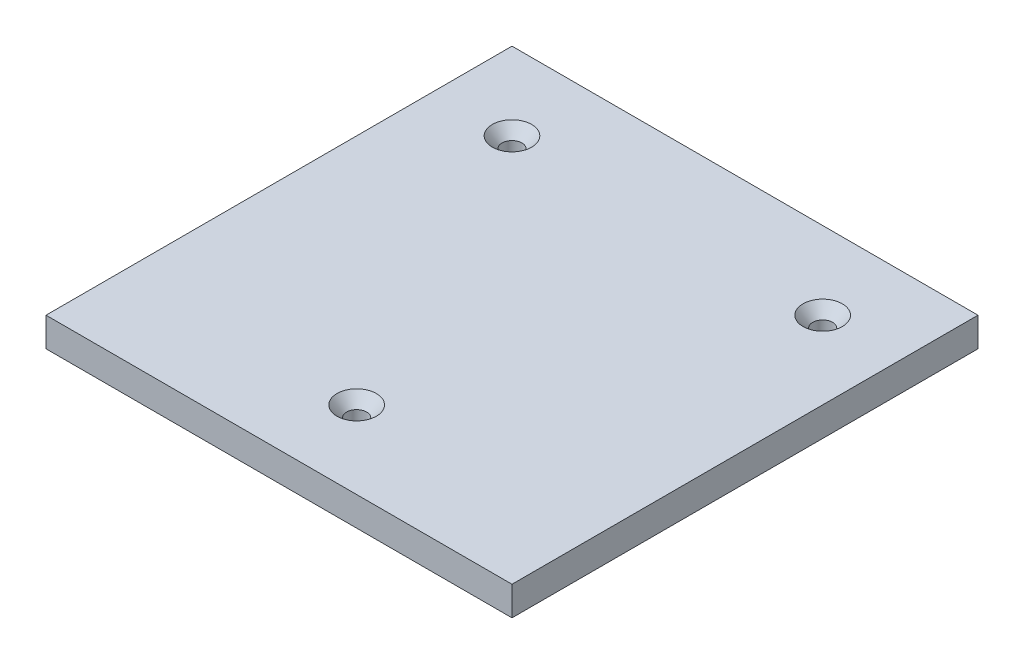
from build123d import *

# Parameters (mm, degrees)
SKETCH1_W                                        = 152.4
SKETCH1_H                                        = 152.4
EXTRUDE1_DEPTH                                   = 9.525
SKETCH16_W                                       = 1.527820346
SKETCH16_H                                       = 0.474151141
CUT_EXTRUDE3_DEPTH                               = 0.127
CSK_FOR_1_4_FLAT_HEAD_MACHINE_SCREW1_D           = 6.5278
CSK_FOR_1_4_FLAT_HEAD_MACHINE_SCREW1_CSINK_D     = 12.8778
CSK_FOR_1_4_FLAT_HEAD_MACHINE_SCREW1_CSINK_ANGLE = 82
LPATTERN2_COUNT                                  = 3
LPATTERN2_PITCH                                  = 50.8
LPATTERN2_COUNT_DIR2                             = 3
LPATTERN2_PITCH_DIR2                             = 50.8


with BuildPart() as part:
    # Sketch1 → Extrude1 (new body)
    with BuildSketch(Plane(origin=(0, 0, 0), x_dir=(1, 0, 0), z_dir=(0, 1, 0))):
        Rectangle(SKETCH1_W, SKETCH1_H)
    extrude(amount=EXTRUDE1_DEPTH)

    # Sketch16 → Cut-Extrude3 (cut)
    with BuildSketch(Plane(origin=(0, 0, -76.2), x_dir=(-1, 0, 0), z_dir=(0, 0, -1))):
        with BuildLine():
            Line((-21.995344635, 2.54), (-21.995344635, 6.649309896))
            Line((-21.995344635, 6.649309896), (-20.456822961, 6.649309896))
            add(Edge.make_bspline(
                [(-20.456822961, 6.649309896), (-20.418670168, 6.649163533), (-20.344223223, 6.648877936), (-20.235515289, 6.641735465), (-20.132560757, 6.631966046), (-20.035137992, 6.619372964), (-19.943668539, 6.601100659), (-19.858237639, 6.578964983), (-19.778400711, 6.553432196), (-19.680812231, 6.514537491), (-19.568352208, 6.454670273), (-19.44789684, 6.365338936), (-19.343095989, 6.258084044), (-19.256860301, 6.135110237), (-19.185811395, 6.003751019), (-19.135438552, 5.866508908), (-19.103232465, 5.726371998), (-19.099578309, 5.63148124), (-19.097754324, 5.584116185)],
                knots=[0, 0, 0, 0, 0.939712594, 1.833646414, 2.682508961, 3.487467313, 4.25240329, 4.978730417, 5.660668875, 6.315918528, 7.564895217, 8.787077865, 9.996481721, 11.241996224, 12.475862915, 13.665015424, 14.834484263, 16, 16, 16, 16], degree=3))
            add(Edge.make_bspline(
                [(-19.097754324, 5.584116185), (-19.099671717, 5.540049426), (-19.103488018, 5.452340752), (-19.133861507, 5.323140541), (-19.181800165, 5.197687941), (-19.249586784, 5.077508077), (-19.33622658, 4.964799613), (-19.443635186, 4.863375963), (-19.57026915, 4.773019762), (-19.665307935, 4.724857251), (-19.714315444, 4.700021868)],
                knots=[0, 0, 0, 0, 0.926741525, 1.844548388, 2.778836836, 3.746021974, 4.738420572, 5.759761325, 6.844803049, 8, 8, 8, 8], degree=3))
            add(Edge.make_bspline(
                [(-19.714315444, 4.700021868), (-19.683999074, 4.690531545), (-19.624644781, 4.671951105), (-19.539316819, 4.637951508), (-19.459219921, 4.5992381), (-19.384179741, 4.555747265), (-19.314703314, 4.507076257), (-19.250986677, 4.453149199), (-19.192588046, 4.394800599), (-19.139611757, 4.33206595), (-19.093077645, 4.265348962), (-19.05134236, 4.196107806), (-19.016879177, 4.123508665), (-18.988630961, 4.047740025), (-18.966593153, 3.96927007), (-18.950767608, 3.887796991), (-18.941747451, 3.803510432), (-18.940392653, 3.746252855), (-18.939703943, 3.717146064)],
                knots=[0, 0, 0, 0, 1.127427615, 2.20731145, 3.257257018, 4.283066884, 5.282973838, 6.264540225, 7.242620376, 8.210460609, 9.17525685, 10.12748095, 11.077310519, 12.023587065, 12.994999128, 13.967387486, 14.966724908, 16, 16, 16, 16], degree=3))
            add(Edge.make_bspline(
                [(-18.939703943, 3.717146064), (-18.941123478, 3.670415518), (-18.943937171, 3.57778989), (-18.966534255, 3.441460543), (-19.00472213, 3.310323201), (-19.057284492, 3.186498196), (-19.119914662, 3.072003749), (-19.191096044, 2.969837698), (-19.269013367, 2.881051323), (-19.355860701, 2.806366113), (-19.451077844, 2.742980225), (-19.557354131, 2.689605162), (-19.673867854, 2.642533471), (-19.802987088, 2.604930867), (-19.944653059, 2.575059407), (-20.100788303, 2.555651871), (-20.2716327, 2.541758677), (-20.390662074, 2.540602609), (-20.452707066, 2.54)],
                knots=[0, 0, 0, 0, 1.028073207, 2.037766189, 3.031549473, 4.027532207, 4.992436545, 5.898794514, 6.762903869, 7.584966804, 8.412380356, 9.273953678, 10.198004568, 11.174406109, 12.229717296, 13.381036288, 14.634844708, 16, 16, 16, 16], degree=3))
            Line((-20.452707066, 2.54), (-21.995344635, 2.54))
        make_face()
        with BuildLine():
            Line((-21.415826573, 4.910755709), (-20.568775314, 4.910755709))
            add(Edge.make_bspline(
                [(-20.568775314, 4.910755709), (-20.541057688, 4.910865371), (-20.487805867, 4.911076055), (-20.410991384, 4.914013623), (-20.340095298, 4.916519789), (-20.275391845, 4.922810073), (-20.216560478, 4.928971126), (-20.163836634, 4.937264865), (-20.116962068, 4.946610026), (-20.088260764, 4.955278367), (-20.074867875, 4.959323274)],
                knots=[0, 0, 0, 0, 1.335841395, 2.566453063, 3.705076039, 4.753984432, 5.69893722, 6.555639608, 7.326018133, 8, 8, 8, 8], degree=3))
            add(Edge.make_bspline(
                [(-20.074867875, 4.959323274), (-20.043399388, 4.970346687), (-19.98273473, 4.991597522), (-19.901438415, 5.039860303), (-19.832197584, 5.097775404), (-19.775197788, 5.166365465), (-19.73139627, 5.245263419), (-19.698918708, 5.332833114), (-19.681136522, 5.430298694), (-19.678595445, 5.49788765), (-19.677272386, 5.533079083)],
                knots=[0, 0, 0, 0, 1.059015028, 2.041559358, 2.989777133, 3.920090524, 4.862499371, 5.848878527, 6.879979022, 8, 8, 8, 8], degree=3))
            add(Edge.make_bspline(
                [(-19.677272386, 5.533079083), (-19.678336215, 5.566900327), (-19.680409494, 5.632814032), (-19.697812823, 5.72853216), (-19.727928642, 5.817580301), (-19.768713706, 5.899938921), (-19.820358435, 5.973208743), (-19.881998221, 6.03620364), (-19.955838332, 6.083825008), (-20.024856719, 6.113531315), (-20.086933288, 6.132115413), (-20.142396523, 6.143110859), (-20.205308373, 6.152798941), (-20.275875865, 6.161035425), (-20.354125692, 6.167427696), (-20.440298956, 6.172505932), (-20.534190527, 6.174662027), (-20.599232437, 6.174989056), (-20.632983281, 6.175158754)],
                knots=[0, 0, 0, 0, 1.216168307, 2.37017178, 3.484610845, 4.588286376, 5.664695412, 6.69777344, 7.738183022, 8.803673002, 9.390844981, 10.0665252, 10.835811589, 11.680682236, 12.621801058, 13.660007223, 14.785756265, 16, 16, 16, 16], degree=3))
            Line((-20.632983281, 6.175158754), (-21.415826573, 6.175158754))
            Line((-21.415826573, 6.175158754), (-21.415826573, 4.910755709))
        make_face(mode=Mode.SUBTRACT)
        with BuildLine():
            Line((-21.415826573, 3.014151142), (-20.443652096, 3.014151142))
            add(Edge.make_bspline(
                [(-20.443652096, 3.014151142), (-20.404961795, 3.014595639), (-20.333877036, 3.015412302), (-20.236646975, 3.017974214), (-20.158055025, 3.024232008), (-20.112161479, 3.030970054), (-20.092154635, 3.033907439)],
                knots=[0, 0, 0, 0, 1.317581857, 2.420761387, 3.311546315, 4, 4, 4, 4], degree=3))
            add(Edge.make_bspline(
                [(-20.092154635, 3.033907439), (-20.06347076, 3.039936499), (-20.007931362, 3.051610318), (-19.929634137, 3.077665063), (-19.85784548, 3.107512163), (-19.793818354, 3.14544451), (-19.734530772, 3.189158942), (-19.68300545, 3.24376036), (-19.635548183, 3.305796815), (-19.594430639, 3.376790482), (-19.561181134, 3.455328392), (-19.535769107, 3.54019708), (-19.52223281, 3.631098978), (-19.52023977, 3.693508068), (-19.519222005, 3.725377855)],
                knots=[0, 0, 0, 0, 1.067651492, 2.067249321, 3.003744366, 3.895862395, 4.774133402, 5.679610569, 6.621910665, 7.616993802, 8.661192143, 9.724711987, 10.838102842, 12, 12, 12, 12], degree=3))
            add(Edge.make_bspline(
                [(-19.519222005, 3.725377855), (-19.520355906, 3.762794894), (-19.522567127, 3.835761941), (-19.543585548, 3.94120302), (-19.578304539, 4.039000932), (-19.627178761, 4.127801275), (-19.687125547, 4.207669537), (-19.759655104, 4.27541961), (-19.844225101, 4.329182643), (-19.941095458, 4.371376219), (-20.054317501, 4.401396222), (-20.187017066, 4.421762975), (-20.341316723, 4.434905153), (-20.451578993, 4.436013834), (-20.5103296, 4.436604567)],
                knots=[0, 0, 0, 0, 0.96167883, 1.875371887, 2.752872588, 3.621584364, 4.472914353, 5.312011319, 6.159851575, 7.038572308, 8.019870099, 9.164119506, 10.488969081, 12, 12, 12, 12], degree=3))
            Line((-20.5103296, 4.436604567), (-21.415826573, 4.436604567))
            Line((-21.415826573, 4.436604567), (-21.415826573, 3.014151142))
        make_face(mode=Mode.SUBTRACT)
        Polygon((-18.764366802, 2.54), (-17.132825894, 6.649309896), (-16.479221716, 6.649309896), (-14.847680808, 2.54), (-15.46259557, 2.54), (-15.930161279, 3.804403045), (-17.681886331, 3.804403045), (-18.14945204, 2.54), align=None)
        with BuildLine():
            Line((-17.507372369, 4.278554187), (-16.104675241, 4.278554187))
            Line((-16.104675241, 4.278554187), (-16.503917088, 5.358565121))
            add(Edge.make_bspline(
                [(-16.503917088, 5.358565121), (-16.519222595, 5.400295272), (-16.549147751, 5.481885595), (-16.593775174, 5.600429448), (-16.634546069, 5.713003557), (-16.674525279, 5.817993769), (-16.710615227, 5.916925173), (-16.743880256, 6.009129533), (-16.77677909, 6.093965984), (-16.796522143, 6.148779072), (-16.806023805, 6.175158754)],
                knots=[0, 0, 0, 0, 1.225184869, 2.395467751, 3.491410812, 4.525364584, 5.492066482, 6.394148129, 7.227157926, 8, 8, 8, 8], degree=3))
            add(Edge.make_bspline(
                [(-16.806023805, 6.175158754), (-16.821741388, 6.110108782), (-16.853241363, 5.979740617), (-16.91919464, 5.788733767), (-16.994642899, 5.59947376), (-17.055915876, 5.477515903), (-17.086727866, 5.416187655)],
                knots=[0, 0, 0, 0, 0.9891762, 1.982431084, 2.985436691, 4, 4, 4, 4], degree=3))
            Line((-17.086727866, 5.416187655), (-17.507372369, 4.278554187))
        make_face(mode=Mode.SUBTRACT)
        Polygon((-14.408926366, 2.54), (-14.408926366, 6.649309896), (-13.829408303, 6.649309896), (-13.829408303, 3.014151142), (-11.880120276, 3.014151142), (-11.880120276, 2.54), align=None)
        with Locations((-10.800109342, 3.988795156)):
            Rectangle(SKETCH16_W, SKETCH16_H)
        Polygon((-8.350328442, 2.54), (-8.350328442, 6.175158754), (-9.667414947, 6.175158754), (-9.667414947, 6.649309896), (-6.453723875, 6.649309896), (-6.453723875, 6.175158754), (-7.77081038, 6.175158754), (-7.77081038, 2.54), align=None)
        Polygon((-5.821522352, 2.54), (-5.821522352, 6.649309896), (-2.923932041, 6.649309896), (-2.923932041, 6.175158754), (-5.24200429, 6.175158754), (-5.24200429, 4.910755709), (-3.081982422, 4.910755709), (-3.081982422, 4.436604567), (-5.24200429, 4.436604567), (-5.24200429, 3.014151142), (-2.818565121, 3.014151142), (-2.818565121, 2.54), align=None)
        with BuildLine():
            Line((0.763910173, 3.990441514), (1.343428235, 3.855440147))
            add(Edge.make_bspline(
                [(1.343428235, 3.855440147), (1.32890969, 3.801123529), (1.300509614, 3.694873482), (1.244359213, 3.542817905), (1.181337275, 3.400120231), (1.109914601, 3.267156352), (1.029309477, 3.144690728), (0.941657612, 3.031149439), (0.843487242, 2.928913554), (0.738400352, 2.835623521), (0.625578728, 2.753341962), (0.50638261, 2.682290325), (0.381388169, 2.621839805), (0.250090215, 2.57212901), (0.112403627, 2.534717374), (-0.030962645, 2.507449582), (-0.180426648, 2.49065421), (-0.282306437, 2.48844305), (-0.334210701, 2.48731654)],
                knots=[0, 0, 0, 0, 1.145254194, 2.240259345, 3.299159039, 4.322497661, 5.312016644, 6.284080175, 7.241264552, 8.196044782, 9.144516039, 10.082428046, 11.020306713, 11.970622414, 12.939253955, 13.924100776, 14.94240044, 16, 16, 16, 16], degree=3))
            add(Edge.make_bspline(
                [(-0.334210701, 2.48731654), (-0.38746548, 2.488090236), (-0.491654201, 2.489603911), (-0.64428467, 2.501915742), (-0.789451234, 2.523268696), (-0.926882797, 2.55293557), (-1.057041938, 2.589616815), (-1.179388922, 2.635765072), (-1.293709454, 2.691047363), (-1.400957119, 2.753917616), (-1.5006764, 2.825341055), (-1.595134949, 2.903390154), (-1.682039625, 2.99021352), (-1.763563375, 3.083761172), (-1.837930581, 3.185267134), (-1.907877229, 3.293352405), (-1.969989263, 3.409921443), (-2.026568509, 3.532813054), (-2.076229322, 3.660837427), (-2.120161771, 3.791465727), (-2.15607895, 3.924958245), (-2.187001323, 4.060191665), (-2.209464929, 4.198303884), (-2.227300336, 4.338258635), (-2.237106602, 4.480913965), (-2.238397003, 4.576805835), (-2.239047059, 4.625112573)],
                knots=[0, 0, 0, 0, 1.180702053, 2.309949215, 3.392367133, 4.431746864, 5.425408375, 6.388154007, 7.326956194, 8.237882283, 9.141054626, 10.043899035, 10.951650021, 11.86168169, 12.792564695, 13.739356664, 14.713891418, 15.718426911, 16.737522708, 17.757217648, 18.772674716, 19.801476837, 20.831699174, 21.873853055, 22.928926693, 24, 24, 24, 24], degree=3))
            add(Edge.make_bspline(
                [(-2.239047059, 4.625112573), (-2.238117342, 4.677261645), (-2.236280456, 4.780295039), (-2.225911268, 4.932323803), (-2.206866827, 5.079050158), (-2.180419637, 5.220570618), (-2.146953362, 5.356999795), (-2.105642997, 5.488404156), (-2.057011117, 5.61461557), (-2.001205983, 5.735773212), (-1.937856835, 5.850524641), (-1.868854388, 5.959032987), (-1.792552667, 6.059516591), (-1.711213906, 6.15389522), (-1.622806613, 6.240597363), (-1.527600747, 6.319819422), (-1.426417702, 6.392284002), (-1.319272247, 6.45731837), (-1.207564899, 6.514382626), (-1.092954872, 6.565210256), (-0.974986311, 6.606870408), (-0.854594506, 6.641509149), (-0.731520263, 6.669084805), (-0.605476007, 6.687524733), (-0.476578205, 6.699541618), (-0.389665239, 6.701170194), (-0.345735208, 6.701993356)],
                knots=[0, 0, 0, 0, 1.185634383, 2.342514083, 3.462112933, 4.547331452, 5.613960142, 6.653690668, 7.676612054, 8.686959706, 9.683658101, 10.654407272, 11.607580201, 12.5494388, 13.484601218, 14.419076806, 15.362504069, 16.311442244, 17.265594461, 18.212500624, 19.159571152, 20.107257795, 21.059246075, 22.024387127, 23.001429356, 24, 24, 24, 24], degree=3))
            add(Edge.make_bspline(
                [(-0.345735208, 6.701993356), (-0.29658342, 6.701066869), (-0.199970716, 6.699245767), (-0.058208785, 6.684266847), (0.077562132, 6.659178796), (0.207930354, 6.626265645), (0.331540467, 6.581200691), (0.449734473, 6.52762364), (0.561336575, 6.463257302), (0.667215134, 6.389870583), (0.765646608, 6.307328138), (0.858008441, 6.217601885), (0.940534603, 6.118449322), (1.016493632, 6.012270118), (1.083495604, 5.897591929), (1.144005452, 5.775414625), (1.196042161, 5.64482996), (1.223884392, 5.553874128), (1.238061315, 5.507560532)],
                knots=[0, 0, 0, 0, 1.098391872, 2.158997981, 3.181470371, 4.182549255, 5.160268219, 6.118029851, 7.079534476, 8.035645336, 8.993622929, 9.94770573, 10.909620999, 11.872786677, 12.862530088, 13.874594564, 14.917769567, 16, 16, 16, 16], degree=3))
            Line((1.238061315, 5.507560532), (0.658543253, 5.383260493))
            add(Edge.make_bspline(
                [(0.658543253, 5.383260493), (0.647162422, 5.4188038), (0.624886616, 5.48837305), (0.585333744, 5.587521594), (0.54261796, 5.679563838), (0.49572174, 5.763874117), (0.44454345, 5.840472628), (0.390261591, 5.910290312), (0.331575622, 5.97202401), (0.269679266, 6.027097149), (0.202974177, 6.074014192), (0.133024212, 6.115590414), (0.058354477, 6.149988398), (-0.019960849, 6.179081986), (-0.102653772, 6.201225341), (-0.189387553, 6.216804065), (-0.280238401, 6.225820267), (-0.342148151, 6.227159288), (-0.373723296, 6.227842214)],
                knots=[0, 0, 0, 0, 1.235697765, 2.418642872, 3.532555292, 4.594392283, 5.610119701, 6.580908344, 7.519430642, 8.427315627, 9.319973334, 10.216139639, 11.118687699, 12.038725643, 12.980015607, 13.949697744, 14.954307006, 16, 16, 16, 16], degree=3))
            add(Edge.make_bspline(
                [(-0.373723296, 6.227842214), (-0.409974451, 6.227316246), (-0.481269776, 6.226281822), (-0.586011184, 6.214960162), (-0.686599367, 6.198284462), (-0.782284644, 6.173277816), (-0.873590612, 6.142101032), (-0.959975445, 6.103280419), (-1.042173971, 6.057778107), (-1.119268812, 6.005320849), (-1.190612056, 5.946348796), (-1.258139753, 5.884006109), (-1.318609823, 5.815385267), (-1.374328171, 5.742748971), (-1.423672282, 5.664813686), (-1.468090248, 5.582640984), (-1.507298938, 5.495557396), (-1.550039072, 5.372993842), (-1.593618368, 5.215134818), (-1.63142346, 5.021966538), (-1.655504413, 4.825754905), (-1.658184632, 4.693779385), (-1.659528996, 4.627582111)],
                knots=[0, 0, 0, 0, 0.935256702, 1.839373932, 2.716087708, 3.564631604, 4.388828665, 5.203538865, 6.005592122, 6.810952829, 7.606223804, 8.392839071, 9.180346482, 9.963639178, 10.753404291, 11.558266631, 12.372976832, 13.215232055, 14.905983541, 16.594894834, 18.292041732, 20, 20, 20, 20], degree=3))
            add(Edge.make_bspline(
                [(-1.659528996, 4.627582111), (-1.658012744, 4.544350116), (-1.655071077, 4.382872509), (-1.626044057, 4.148864784), (-1.581788384, 3.930598565), (-1.528378163, 3.760307425), (-1.474802345, 3.634697473), (-1.431472916, 3.546731013), (-1.3820141, 3.465331117), (-1.32765612, 3.390035508), (-1.267698787, 3.321063819), (-1.202977429, 3.258049668), (-1.133477588, 3.200386711), (-1.058375757, 3.150774256), (-0.980562698, 3.106722721), (-0.90102035, 3.067551255), (-0.819698632, 3.034421763), (-0.736269445, 3.008686101), (-0.651904359, 2.986446911), (-0.565674179, 2.971919228), (-0.477603494, 2.963720262), (-0.418466207, 2.962224562), (-0.388540519, 2.961467682)],
                knots=[0, 0, 0, 0, 2.10686522, 4.087509323, 5.961373225, 7.741398778, 8.594514555, 9.418024779, 10.222433421, 11.003575649, 11.767087398, 12.533660211, 13.289033706, 14.050297079, 14.809623433, 15.552362432, 16.294320901, 17.0305302, 17.761969017, 18.502233515, 19.242073914, 20, 20, 20, 20], degree=3))
            add(Edge.make_bspline(
                [(-0.388540519, 2.961467682), (-0.352828308, 2.962216642), (-0.282284064, 2.963696103), (-0.178857244, 2.97664591), (-0.079155216, 2.995729144), (0.015614145, 3.025176502), (0.106725593, 3.061231342), (0.193432627, 3.105693264), (0.275462566, 3.15916798), (0.353780262, 3.219883497), (0.426941469, 3.28896738), (0.493989781, 3.365863056), (0.554139693, 3.45092108), (0.609913797, 3.542776396), (0.656774296, 3.644173061), (0.700178182, 3.752088887), (0.736345436, 3.868297566), (0.754589937, 3.949141993), (0.763910173, 3.990441514)],
                knots=[0, 0, 0, 0, 1.013374089, 2.001772144, 2.95501459, 3.891367103, 4.814208647, 5.733921849, 6.652182523, 7.590185968, 8.54346024, 9.504121027, 10.481158517, 11.497760682, 12.549996529, 13.647863555, 14.798406869, 16, 16, 16, 16], degree=3))
        make_face()
        with BuildLine():
            Line((5.031270449, 3.962453425), (5.610788512, 3.962453425))
            add(Edge.make_bspline(
                [(5.610788512, 3.962453425), (5.617162874, 3.910420672), (5.629408368, 3.810462952), (5.663647991, 3.668787931), (5.707716595, 3.541407547), (5.762624861, 3.426631237), (5.834854593, 3.325835164), (5.921878995, 3.234918645), (6.027565395, 3.156190445), (6.146861249, 3.086127505), (6.279723537, 3.031117016), (6.421565879, 2.990336835), (6.571711811, 2.966174253), (6.674522506, 2.96305859), (6.727019325, 2.961467682)],
                knots=[0, 0, 0, 0, 1.125557648, 2.162256852, 3.1243583, 4.018160113, 4.88511607, 5.777380551, 6.711250965, 7.707237736, 8.743031335, 9.791730543, 10.872421559, 12, 12, 12, 12], degree=3))
            add(Edge.make_bspline(
                [(6.727019325, 2.961467682), (6.773474488, 2.962327517), (6.864053062, 2.96400403), (6.995085094, 2.984143104), (7.118386616, 3.012709839), (7.23166286, 3.055921499), (7.334495959, 3.108394002), (7.423794986, 3.171860726), (7.500033745, 3.243433756), (7.559734219, 3.324998286), (7.606633719, 3.410464274), (7.641039351, 3.498314495), (7.661534081, 3.588061341), (7.664145643, 3.648447645), (7.66544346, 3.678456648)],
                knots=[0, 0, 0, 0, 1.267006637, 2.470417599, 3.611360613, 4.716023143, 5.771382139, 6.754486395, 7.697536124, 8.612899418, 9.501261124, 10.352596716, 11.181322154, 12, 12, 12, 12], degree=3))
            add(Edge.make_bspline(
                [(7.66544346, 3.678456648), (7.664056069, 3.708161677), (7.661344417, 3.766220113), (7.643673331, 3.850745944), (7.610086933, 3.928111632), (7.566504723, 4.001474882), (7.505874428, 4.06854968), (7.429274892, 4.130353123), (7.335018436, 4.186384723), (7.264670171, 4.217070893), (7.227512197, 4.233279338)],
                knots=[0, 0, 0, 0, 0.942140154, 1.841411588, 2.718743672, 3.605002079, 4.535543111, 5.568170452, 6.715506882, 8, 8, 8, 8], degree=3))
            add(Edge.make_bspline(
                [(7.227512197, 4.233279338), (7.2130349, 4.239220343), (7.180328057, 4.252642152), (7.124270063, 4.270410316), (7.057750154, 4.293386365), (6.979170243, 4.317047957), (6.888951001, 4.342078611), (6.787242636, 4.370409517), (6.67410198, 4.400537884), (6.552737898, 4.43260625), (6.430197159, 4.46521486), (6.313123798, 4.497854008), (6.20541074, 4.530986923), (6.106175671, 4.562889346), (6.015930191, 4.594923389), (5.934418163, 4.626212027), (5.861537962, 4.656120456), (5.81702551, 4.678111666), (5.796003801, 4.688497361)],
                knots=[0, 0, 0, 0, 0.499201778, 1.127787504, 1.87543728, 2.745208432, 3.745951656, 4.863402235, 6.114490242, 7.482339553, 8.869366102, 10.161191451, 11.360587006, 12.46547846, 13.487450326, 14.41601931, 15.251940103, 16, 16, 16, 16], degree=3))
            add(Edge.make_bspline(
                [(5.796003801, 4.688497361), (5.747638713, 4.714625575), (5.654281506, 4.765059828), (5.528633046, 4.855236412), (5.422761462, 4.955304023), (5.337113407, 5.065117558), (5.269994377, 5.182819807), (5.224709462, 5.308610865), (5.193693033, 5.440207389), (5.190794467, 5.530700631), (5.18932083, 5.576707573)],
                knots=[0, 0, 0, 0, 1.158441928, 2.236094408, 3.251151369, 4.220012324, 5.163146324, 6.095083285, 7.031536583, 8, 8, 8, 8], degree=3))
            add(Edge.make_bspline(
                [(5.18932083, 5.576707573), (5.191276639, 5.627652491), (5.195166729, 5.728981563), (5.22967396, 5.877675659), (5.284713653, 6.020758931), (5.347365539, 6.134354839), (5.408464972, 6.220255556), (5.459116867, 6.282119683), (5.515932874, 6.339304751), (5.577163257, 6.392609025), (5.643902572, 6.441236078), (5.714495009, 6.487184422), (5.791495621, 6.526678125), (5.899692931, 6.576944695), (6.044434863, 6.627140566), (6.22664685, 6.670879901), (6.418418984, 6.696637086), (6.549135375, 6.700182678), (6.615890151, 6.701993356)],
                knots=[0, 0, 0, 0, 1.199927478, 2.386647047, 3.578628709, 4.806592355, 5.433127754, 6.062729195, 6.689531802, 7.331674828, 7.974827539, 8.635320743, 9.315455226, 10.01318112, 11.447700238, 12.918145351, 14.426146008, 16, 16, 16, 16], degree=3))
            add(Edge.make_bspline(
                [(6.615890151, 6.701993356), (6.688957686, 6.700319125), (6.831234257, 6.697059075), (7.037966136, 6.66993605), (7.230790384, 6.623358679), (7.382009775, 6.571219985), (7.493804503, 6.518436632), (7.57322659, 6.477250317), (7.646945992, 6.429631435), (7.715626333, 6.378100355), (7.77990556, 6.322680611), (7.838131552, 6.26205395), (7.892832644, 6.198288845), (7.95711405, 6.106742132), (8.026423033, 5.985580576), (8.086350083, 5.828610968), (8.127520666, 5.662942434), (8.135529291, 5.548411536), (8.139594601, 5.490273771)],
                knots=[0, 0, 0, 0, 1.607600973, 3.130308851, 4.577334065, 5.967726088, 6.640410691, 7.296826776, 7.935019992, 8.569057421, 9.185393759, 9.8003086, 10.417295362, 11.032210203, 12.259799365, 13.477607022, 14.719591916, 16, 16, 16, 16], degree=3))
            Line((8.139594601, 5.490273771), (7.560076539, 5.490273771))
            add(Edge.make_bspline(
                [(7.560076539, 5.490273771), (7.556394367, 5.519698994), (7.549189447, 5.577275433), (7.531314997, 5.660625991), (7.506258614, 5.738038239), (7.476909912, 5.810234098), (7.44133314, 5.876462652), (7.399860918, 5.93735984), (7.351988204, 5.992208188), (7.298946811, 6.042457001), (7.239122701, 6.086209691), (7.172823267, 6.124188369), (7.099936596, 6.156271655), (7.020526898, 6.182548913), (6.934578454, 6.202923271), (6.841895772, 6.217911038), (6.742514676, 6.225586944), (6.674072463, 6.227077216), (6.638939165, 6.227842214)],
                knots=[0, 0, 0, 0, 1.074487479, 2.102453544, 3.083708351, 4.020042547, 4.923259678, 5.803182661, 6.684453325, 7.556870173, 8.445961597, 9.363679789, 10.320905216, 11.327237703, 12.390948353, 13.519046902, 14.726457512, 16, 16, 16, 16], degree=3))
            add(Edge.make_bspline(
                [(6.638939165, 6.227842214), (6.602419739, 6.227566948), (6.531727114, 6.2270341), (6.429532907, 6.217320955), (6.334812086, 6.203994174), (6.247727345, 6.184336039), (6.168563963, 6.158603475), (6.09614704, 6.128888268), (6.032503242, 6.09123134), (5.976148921, 6.04928642), (5.927536182, 6.002876683), (5.885639202, 5.953972041), (5.84858456, 5.904009347), (5.819792285, 5.850257608), (5.796351046, 5.794752484), (5.781228871, 5.736450661), (5.770522017, 5.67643057), (5.769407687, 5.635477659), (5.768838892, 5.61457381)],
                knots=[0, 0, 0, 0, 1.464176581, 2.834285765, 4.113735764, 5.29917439, 6.409476712, 7.449999357, 8.431575861, 9.367089851, 10.262376129, 11.120706676, 11.948504824, 12.751342953, 13.560717798, 14.359016663, 15.162382702, 16, 16, 16, 16], degree=3))
            add(Edge.make_bspline(
                [(5.768838892, 5.61457381), (5.770336503, 5.579219114), (5.773243228, 5.510598909), (5.802925141, 5.413110282), (5.84857613, 5.324243082), (5.893549627, 5.275890893), (5.916187945, 5.251551842)],
                knots=[0, 0, 0, 0, 1.050964922, 2.039826012, 3.013306874, 4, 4, 4, 4], degree=3))
            add(Edge.make_bspline(
                [(5.916187945, 5.251551842), (5.930458899, 5.23938835), (5.962018233, 5.212489537), (6.020739238, 5.176892107), (6.093544576, 5.140925441), (6.180920719, 5.105171792), (6.282717335, 5.069197114), (6.398770222, 5.032156759), (6.529521414, 4.995368761), (6.67098627, 4.959917439), (6.813898762, 4.924323599), (6.949713675, 4.888865418), (7.074414754, 4.85526082), (7.187804153, 4.822485039), (7.289999232, 4.790630754), (7.380644827, 4.759030575), (7.460474294, 4.729966426), (7.509379274, 4.709517425), (7.532088451, 4.700021868)],
                knots=[0, 0, 0, 0, 0.523891492, 1.158553688, 1.913783773, 2.794766643, 3.797521443, 4.933638669, 6.202080764, 7.596537849, 9.013317056, 10.322179469, 11.523240428, 12.626146501, 13.623953177, 14.517289671, 15.311498917, 16, 16, 16, 16], degree=3))
            add(Edge.make_bspline(
                [(7.532088451, 4.700021868), (7.561634243, 4.686399361), (7.619627681, 4.659660662), (7.701783152, 4.614008355), (7.77844312, 4.566600892), (7.848988223, 4.516161904), (7.913190354, 4.462585294), (7.97176737, 4.406484932), (8.025073053, 4.34817611), (8.070956526, 4.285792608), (8.112155177, 4.221856247), (8.148206739, 4.155473435), (8.177234765, 4.086253787), (8.202694155, 4.015031681), (8.221006758, 3.941014921), (8.235367533, 3.864951125), (8.243743933, 3.786482772), (8.24455215, 3.733354726), (8.244961522, 3.706444736)],
                knots=[0, 0, 0, 0, 1.198900896, 2.353241543, 3.461831299, 4.520043694, 5.547003373, 6.541368882, 7.508191797, 8.454912692, 9.392021408, 10.310662301, 11.235020644, 12.156274873, 13.095836685, 14.042125239, 15.00831306, 16, 16, 16, 16], degree=3))
            add(Edge.make_bspline(
                [(8.244961522, 3.706444736), (8.242816951, 3.65273971), (8.238559265, 3.546117385), (8.201899051, 3.388951145), (8.144307793, 3.236657936), (8.076767779, 3.115804886), (8.012922051, 3.023490719), (7.959288627, 2.957139515), (7.899812245, 2.895787715), (7.835957151, 2.837513285), (7.767227571, 2.783505214), (7.693044071, 2.73374511), (7.614189625, 2.687714976), (7.501587459, 2.631624561), (7.352033075, 2.572948662), (7.161530814, 2.52408536), (6.960764504, 2.492386528), (6.822905963, 2.489029891), (6.752537876, 2.48731654)],
                knots=[0, 0, 0, 0, 1.197055466, 2.376552968, 3.581957237, 4.820753935, 5.454298064, 6.085440993, 6.72202542, 7.359198513, 8.013298489, 8.67051481, 9.351020706, 10.049282741, 11.476266879, 12.925760103, 14.430794493, 16, 16, 16, 16], degree=3))
            add(Edge.make_bspline(
                [(6.752537876, 2.48731654), (6.707796385, 2.487685767), (6.620154197, 2.48840903), (6.49137379, 2.497167977), (6.367961172, 2.509838224), (6.250037455, 2.528710699), (6.137972437, 2.55347036), (6.031363856, 2.583201928), (5.929959018, 2.617443959), (5.834112235, 2.657711993), (5.744073708, 2.70449905), (5.658224453, 2.754970447), (5.577967733, 2.81218214), (5.503134598, 2.875235136), (5.431828934, 2.942307889), (5.367006151, 3.016139596), (5.306462438, 3.094571151), (5.251581202, 3.17832039), (5.202553173, 3.266291596), (5.158463007, 3.357007387), (5.121316425, 3.451125835), (5.091379814, 3.548171267), (5.066021989, 3.647494255), (5.048436924, 3.749923476), (5.035507791, 3.855137338), (5.03269124, 3.926470103), (5.031270449, 3.962453425)],
                knots=[0, 0, 0, 0, 1.259822038, 2.467811403, 3.633536148, 4.752793854, 5.829021491, 6.863980041, 7.868367876, 8.841470325, 9.788447787, 10.724101269, 11.643985084, 12.560193707, 13.478453146, 14.398077254, 15.323914234, 16.266973849, 17.21495974, 18.158525798, 19.105629373, 20.061269543, 21.017128399, 21.990322895, 22.986232211, 24, 24, 24, 24], degree=3))
        make_face()
        with BuildLine():
            Line((9.035213425, 2.54), (9.035213425, 6.649309896))
            Line((9.035213425, 6.649309896), (10.544923831, 6.649309896))
            add(Edge.make_bspline(
                [(10.544923831, 6.649309896), (10.607500111, 6.648953394), (10.725018657, 6.648283881), (10.889131797, 6.640443025), (11.030058416, 6.630742589), (11.11517866, 6.616931692), (11.15407634, 6.61062048)],
                knots=[0, 0, 0, 0, 1.22865052, 2.30741144, 3.226532197, 4, 4, 4, 4], degree=3))
            add(Edge.make_bspline(
                [(11.15407634, 6.61062048), (11.201522119, 6.601489433), (11.293485265, 6.58379092), (11.423690826, 6.541123645), (11.542315634, 6.488027477), (11.649174302, 6.421875131), (11.746042083, 6.344162306), (11.831538501, 6.251044098), (11.907324622, 6.144599674), (11.971765974, 6.02491232), (12.025403527, 5.896128778), (12.062971478, 5.758929745), (12.087033818, 5.615698867), (12.089566539, 5.51781158), (12.090854117, 5.468047937)],
                knots=[0, 0, 0, 0, 1.070909925, 2.075721949, 3.031861647, 3.947440733, 4.85625699, 5.777986723, 6.742441087, 7.747548058, 8.78749499, 9.830146138, 10.896896232, 12, 12, 12, 12], degree=3))
            add(Edge.make_bspline(
                [(12.090854117, 5.468047937), (12.089946708, 5.425470182), (12.088161331, 5.341696116), (12.072830585, 5.218619924), (12.048650684, 5.100215623), (12.012583082, 4.987293472), (11.96848947, 4.8785333), (11.912921331, 4.775769374), (11.848033421, 4.677606246), (11.773586853, 4.584311026), (11.685942565, 4.497776888), (11.580495712, 4.424369684), (11.459279321, 4.362728268), (11.322265118, 4.312922671), (11.16978571, 4.273733691), (11.001341491, 4.245020483), (10.81660433, 4.229168403), (10.68818669, 4.226998101), (10.621479484, 4.225870726)],
                knots=[0, 0, 0, 0, 0.928769099, 1.82740408, 2.702266355, 3.562020322, 4.410419678, 5.259600434, 6.10654066, 6.975254961, 7.860221694, 8.783881459, 9.766664779, 10.81996744, 11.958551584, 13.197863772, 14.544415867, 16, 16, 16, 16], degree=3))
            Line((10.621479484, 4.225870726), (9.614731487, 4.225870726))
            Line((9.614731487, 4.225870726), (9.614731487, 2.54))
            Line((9.614731487, 2.54), (9.035213425, 2.54))
        make_face()
        with BuildLine():
            Line((9.614731487, 4.700021868), (10.605839082, 4.700021868))
            add(Edge.make_bspline(
                [(10.605839082, 4.700021868), (10.645368348, 4.700682813), (10.721517814, 4.701956061), (10.831550321, 4.710841477), (10.93253301, 4.726221723), (11.024746, 4.747672663), (11.108306708, 4.774335566), (11.183065625, 4.8080568), (11.248637244, 4.848507336), (11.305456059, 4.895274979), (11.3542286, 4.947666149), (11.396488847, 5.004822025), (11.432395437, 5.067151049), (11.46054196, 5.134914), (11.484385946, 5.206792757), (11.499268898, 5.284276653), (11.509616968, 5.366242057), (11.510754991, 5.422738058), (11.511336054, 5.451584355)],
                knots=[0, 0, 0, 0, 1.403696362, 2.704090955, 3.91683431, 5.027708188, 6.063065288, 7.026749679, 7.932587242, 8.790956304, 9.632005367, 10.468072405, 11.310475089, 12.179234342, 13.069796908, 13.994719932, 14.976123913, 16, 16, 16, 16], degree=3))
            add(Edge.make_bspline(
                [(11.511336054, 5.451584355), (11.510108479, 5.493416087), (11.507729865, 5.574471377), (11.483764745, 5.691107444), (11.446192499, 5.798881237), (11.3924001, 5.89575226), (11.327295651, 5.980733949), (11.25076675, 6.050262958), (11.165266936, 6.105848839), (11.101428708, 6.127858137), (11.069288896, 6.138938875)],
                knots=[0, 0, 0, 0, 1.143156811, 2.215038775, 3.243253804, 4.254666983, 5.233799895, 6.158487526, 7.072877374, 8, 8, 8, 8], degree=3))
            add(Edge.make_bspline(
                [(11.069288896, 6.138938875), (11.057518267, 6.141817054), (11.03193988, 6.148071535), (10.989569483, 6.155170465), (10.940464425, 6.161892521), (10.884385344, 6.166352292), (10.821843666, 6.170781412), (10.752648195, 6.172823126), (10.676641304, 6.174586585), (10.623676035, 6.174962204), (10.595960933, 6.175158754)],
                knots=[0, 0, 0, 0, 0.611063981, 1.327884044, 2.165719042, 3.110592661, 4.16481496, 5.328235826, 6.601947678, 8, 8, 8, 8], degree=3))
            Line((10.595960933, 6.175158754), (9.614731487, 6.175158754))
            Line((9.614731487, 6.175158754), (9.614731487, 4.700021868))
        make_face(mode=Mode.SUBTRACT)
        with Locations((13.276231971, 3.988795156)):
            Rectangle(SKETCH16_W, SKETCH16_H)
        with BuildLine():
            Line((17.095782836, 5.595640692), (16.568948234, 5.542957232))
            add(Edge.make_bspline(
                [(16.568948234, 5.542957232), (16.557579567, 5.588267818), (16.536179801, 5.673558024), (16.491304693, 5.789241321), (16.441853281, 5.887089714), (16.398890752, 5.939778372), (16.37879387, 5.964424913)],
                knots=[0, 0, 0, 0, 1.199207122, 2.257322842, 3.184815751, 4, 4, 4, 4], degree=3))
            add(Edge.make_bspline(
                [(16.37879387, 5.964424913), (16.361543034, 5.981235207), (16.327614633, 6.014297165), (16.271916548, 6.057393663), (16.213201547, 6.093907178), (16.151292171, 6.123488661), (16.086522879, 6.146856334), (16.018625386, 6.163203266), (15.947753507, 6.173322944), (15.899463173, 6.174541607), (15.875008281, 6.175158754)],
                knots=[0, 0, 0, 0, 1.028360939, 2.022547923, 3.001693811, 3.976902288, 4.948369586, 5.937776631, 6.955661634, 8, 8, 8, 8], degree=3))
            add(Edge.make_bspline(
                [(15.875008281, 6.175158754), (15.835362695, 6.173882215), (15.757024746, 6.171359831), (15.642088976, 6.146665875), (15.530454034, 6.109707432), (15.461292061, 6.07224243), (15.426375691, 6.053328252)],
                knots=[0, 0, 0, 0, 1.010336883, 1.996381556, 2.988474728, 4, 4, 4, 4], degree=3))
            add(Edge.make_bspline(
                [(15.426375691, 6.053328252), (15.392037607, 6.024878262), (15.321549737, 5.96647724), (15.229562197, 5.858564387), (15.147298953, 5.732921598), (15.086628327, 5.615624485), (15.043930269, 5.510457309), (15.016315488, 5.420325839), (14.992722092, 5.320749111), (14.973067462, 5.211914742), (14.957865871, 5.093734449), (14.945160384, 4.966133176), (14.938133172, 4.82878739), (14.936568025, 4.734053503), (14.935760968, 4.685204645)],
                knots=[0, 0, 0, 0, 1.063306303, 2.18271343, 3.369442992, 4.644240368, 5.329284104, 6.077448525, 6.892756613, 7.771869145, 8.717113863, 9.73749892, 10.833357348, 12, 12, 12, 12], degree=3))
            add(Edge.make_bspline(
                [(14.935760968, 4.685204645), (14.966821362, 4.728843569), (15.027623978, 4.814269426), (15.13488439, 4.926012785), (15.252007806, 5.020471386), (15.379125173, 5.095890251), (15.512919604, 5.15434174), (15.650440766, 5.196402845), (15.791447641, 5.222221065), (15.886425257, 5.225303479), (15.934277174, 5.22685647)],
                knots=[0, 0, 0, 0, 1.083917396, 2.121834425, 3.126226247, 4.123362703, 5.106535049, 6.077135049, 7.031216202, 8, 8, 8, 8], degree=3))
            add(Edge.make_bspline(
                [(15.934277174, 5.22685647), (15.975489401, 5.225747646), (16.056911992, 5.223556953), (16.17681598, 5.206196724), (16.291768559, 5.175832487), (16.402765916, 5.136276097), (16.507675035, 5.082265917), (16.609056301, 5.019143922), (16.704561713, 4.942331696), (16.795399993, 4.856024404), (16.878104713, 4.76006989), (16.951304257, 4.656795511), (17.012304045, 4.545953726), (17.06176782, 4.428286855), (17.100481868, 4.304223064), (17.128612221, 4.173410048), (17.145079354, 4.035589261), (17.147322189, 3.941369454), (17.148466296, 3.893306384)],
                knots=[0, 0, 0, 0, 0.981553735, 1.939246043, 2.877808487, 3.810434071, 4.740031046, 5.683044261, 6.650811044, 7.654063953, 8.664382933, 9.663624521, 10.66421212, 11.671863278, 12.699354266, 13.755775259, 14.855184124, 16, 16, 16, 16], degree=3))
            add(Edge.make_bspline(
                [(17.148466296, 3.893306384), (17.146416463, 3.829787327), (17.142371167, 3.704433991), (17.10990133, 3.519834448), (17.057581017, 3.341898333), (16.994992679, 3.200988354), (16.937490335, 3.093036254), (16.888664117, 3.017529765), (16.836455118, 2.946572687), (16.781852271, 2.879188597), (16.720895188, 2.818461547), (16.657279435, 2.761530114), (16.588902271, 2.71036257), (16.517774745, 2.663256406), (16.442553207, 2.622410556), (16.365426402, 2.586114605), (16.285759434, 2.555197131), (16.203295062, 2.530921695), (16.118455631, 2.510838132), (16.030958756, 2.49702883), (15.941034714, 2.488512284), (15.880240987, 2.487718207), (15.84948973, 2.48731654)],
                knots=[0, 0, 0, 0, 1.777979151, 3.508799182, 5.232661887, 6.960203328, 7.816385973, 8.656273476, 9.47551652, 10.283326439, 11.082130802, 11.882412381, 12.672407567, 13.471692325, 14.269609044, 15.067192643, 15.857822979, 16.66013129, 17.472860815, 18.297850482, 19.139002666, 20, 20, 20, 20], degree=3))
            add(Edge.make_bspline(
                [(15.84948973, 2.48731654), (15.797556611, 2.488756673), (15.69570663, 2.491581028), (15.546634285, 2.513278997), (15.405083574, 2.549539351), (15.270753394, 2.600235427), (15.143234536, 2.664238182), (15.023783669, 2.744470048), (14.911739836, 2.838552026), (14.807016663, 2.947029755), (14.712064254, 3.072288906), (14.630913647, 3.216876402), (14.561766127, 3.379526602), (14.5051749, 3.56068701), (14.462351677, 3.760547075), (14.431517151, 3.978677558), (14.41255426, 4.215109703), (14.410163935, 4.378945165), (14.408926366, 4.463769476)],
                knots=[0, 0, 0, 0, 0.898506621, 1.76212948, 2.600594211, 3.422599815, 4.24233914, 5.064166416, 5.906856258, 6.769969817, 7.668413694, 8.619051846, 9.63165591, 10.722000005, 11.898403521, 13.164960021, 14.532183992, 16, 16, 16, 16], degree=3))
            add(Edge.make_bspline(
                [(14.408926366, 4.463769476), (14.409131572, 4.512071174), (14.409536309, 4.607338633), (14.41604007, 4.747548587), (14.423500687, 4.882955189), (14.436283277, 5.013018227), (14.451376161, 5.138322685), (14.471630612, 5.258131678), (14.493381451, 5.373376453), (14.519826034, 5.483149656), (14.549305278, 5.588483969), (14.583236914, 5.688221994), (14.619077127, 5.783654167), (14.659737103, 5.873275047), (14.703071165, 5.958544252), (14.750970627, 6.037883851), (14.801204149, 6.113107969), (14.838288623, 6.15949352), (14.856735777, 6.182567366)],
                knots=[0, 0, 0, 0, 1.28053818, 2.525659045, 3.721026795, 4.875695215, 5.990149104, 7.066600796, 8.096771069, 9.099076143, 10.059445332, 10.995815448, 11.891625124, 12.761078582, 13.603822678, 14.426062074, 15.217066536, 16, 16, 16, 16], degree=3))
            add(Edge.make_bspline(
                [(14.856735777, 6.182567366), (14.889921876, 6.21989519), (14.955334758, 6.293471797), (15.067235633, 6.388515345), (15.186475441, 6.469697157), (15.314955915, 6.535285033), (15.451695068, 6.586419447), (15.596778625, 6.6235385), (15.750611438, 6.645064989), (15.855732794, 6.647871992), (15.909581802, 6.649309896)],
                knots=[0, 0, 0, 0, 1.005002357, 1.980952959, 2.948226316, 3.90482984, 4.879026092, 5.883055346, 6.915583142, 8, 8, 8, 8], degree=3))
            add(Edge.make_bspline(
                [(15.909581802, 6.649309896), (15.949678368, 6.648601112), (16.0284513, 6.64720865), (16.143873751, 6.633847835), (16.253660785, 6.611517237), (16.358056926, 6.581395756), (16.456455138, 6.541300219), (16.549989834, 6.493782667), (16.637711244, 6.436622038), (16.718984312, 6.370599274), (16.794010348, 6.29758594), (16.861210124, 6.216968906), (16.920330438, 6.129752938), (16.971833615, 6.035756646), (17.01525943, 5.935424978), (17.050914182, 5.828326719), (17.078014173, 5.714489392), (17.089777849, 5.635806061), (17.095782836, 5.595640692)],
                knots=[0, 0, 0, 0, 1.095988384, 2.15315746, 3.171326302, 4.156539379, 5.119213808, 6.072133135, 7.021027441, 7.975952916, 8.930907862, 9.879001051, 10.840359051, 11.807350428, 12.805278655, 13.825435679, 14.889953203, 16, 16, 16, 16], degree=3))
        make_face()
        with BuildLine():
            add(Edge.make_bspline(
                [(14.935760968, 3.904007712), (14.937226337, 3.862756803), (14.940137838, 3.780796531), (14.962407505, 3.659140564), (14.998775442, 3.540442989), (15.048618114, 3.426022053), (15.110164635, 3.319713398), (15.183267556, 3.225516593), (15.266340105, 3.144814682), (15.358935832, 3.077432542), (15.460837387, 3.025651226), (15.570219692, 2.98814809), (15.687213427, 2.965481071), (15.767893163, 2.962825685), (15.809153956, 2.961467682)],
                knots=[0, 0, 0, 0, 1.034121613, 2.054667162, 3.090870403, 4.141799978, 5.178094622, 6.163726224, 7.122467907, 8.07367165, 9.024701118, 9.977919151, 10.965878387, 12, 12, 12, 12], degree=3))
            add(Edge.make_bspline(
                [(15.809153956, 2.961467682), (15.838556962, 2.962262885), (15.89594903, 2.963815052), (15.979980337, 2.975842784), (16.06015549, 2.99433786), (16.136010251, 3.021664209), (16.207441679, 3.056540145), (16.274820666, 3.09898645), (16.33810364, 3.149130203), (16.396525459, 3.206879361), (16.449326144, 3.271106803), (16.495202938, 3.341418399), (16.535716433, 3.41665734), (16.566189048, 3.498672593), (16.591019818, 3.585363009), (16.609275176, 3.677548272), (16.619992991, 3.775334227), (16.621077549, 3.842516591), (16.621631694, 3.876842803)],
                knots=[0, 0, 0, 0, 1.023436885, 1.997658284, 2.950132304, 3.883974581, 4.798406504, 5.712938251, 6.651509614, 7.604127386, 8.56812849, 9.540661787, 10.523651728, 11.536824179, 12.580180944, 13.661349568, 14.805088061, 16, 16, 16, 16], degree=3))
            add(Edge.make_bspline(
                [(16.621631694, 3.876842803), (16.621117733, 3.909805764), (16.620112617, 3.974268995), (16.608802972, 4.068334547), (16.592327531, 4.157259843), (16.567035817, 4.240296637), (16.53599457, 4.318324011), (16.497100225, 4.3907583), (16.451780963, 4.458215125), (16.398645992, 4.518908266), (16.340539102, 4.574203284), (16.276722358, 4.622232285), (16.207961645, 4.662795383), (16.13400891, 4.696003115), (16.054724849, 4.721452933), (15.970273635, 4.739090278), (15.881130453, 4.751401915), (15.819899399, 4.752264197), (15.78857448, 4.752705329)],
                knots=[0, 0, 0, 0, 1.155658139, 2.260035327, 3.319019312, 4.323913291, 5.299809325, 6.260058621, 7.202437855, 8.144128683, 9.083751266, 10.011616631, 10.939332216, 11.87851101, 12.849505762, 13.853846437, 14.90205895, 16, 16, 16, 16], degree=3))
            add(Edge.make_bspline(
                [(15.78857448, 4.752705329), (15.75944226, 4.752250159), (15.702034452, 4.751353204), (15.617845417, 4.738945499), (15.536704279, 4.721272808), (15.458935008, 4.695561529), (15.384510847, 4.662450299), (15.313448305, 4.62217442), (15.246364485, 4.573580106), (15.1826477, 4.519160064), (15.124506902, 4.458706904), (15.073496862, 4.393303774), (15.03189094, 4.322529901), (14.995520609, 4.248116705), (14.968873335, 4.168310047), (14.949913464, 4.084179892), (14.938158828, 3.995710707), (14.93657269, 3.93505096), (14.935760968, 3.904007712)],
                knots=[0, 0, 0, 0, 1.036988316, 2.04348404, 3.025371103, 3.992992706, 4.955812186, 5.923433788, 6.897355974, 7.902569022, 8.905116476, 9.880852345, 10.849905012, 11.825004025, 12.826645469, 13.839294292, 14.894236693, 16, 16, 16, 16], degree=3))
        make_face(mode=Mode.SUBTRACT)
        with Locations((18.333844151, 3.988795156)):
            Rectangle(SKETCH16_W, SKETCH16_H)
        with BuildLine():
            Line((22.153395015, 5.595640692), (21.626560413, 5.542957232))
            add(Edge.make_bspline(
                [(21.626560413, 5.542957232), (21.615191746, 5.588267818), (21.593791981, 5.673558024), (21.548916872, 5.789241321), (21.49946546, 5.887089714), (21.456502931, 5.939778372), (21.436406049, 5.964424913)],
                knots=[0, 0, 0, 0, 1.199207122, 2.257322842, 3.184815751, 4, 4, 4, 4], degree=3))
            add(Edge.make_bspline(
                [(21.436406049, 5.964424913), (21.419155213, 5.981235207), (21.385226813, 6.014297165), (21.329528728, 6.057393663), (21.270813727, 6.093907178), (21.20890435, 6.123488661), (21.144135059, 6.146856334), (21.076237566, 6.163203266), (21.005365687, 6.173322944), (20.957075353, 6.174541607), (20.932620461, 6.175158754)],
                knots=[0, 0, 0, 0, 1.028360939, 2.022547923, 3.001693811, 3.976902288, 4.948369586, 5.937776631, 6.955661634, 8, 8, 8, 8], degree=3))
            add(Edge.make_bspline(
                [(20.932620461, 6.175158754), (20.892974874, 6.173882215), (20.814636926, 6.171359831), (20.699701155, 6.146665875), (20.588066213, 6.109707432), (20.51890424, 6.07224243), (20.48398787, 6.053328252)],
                knots=[0, 0, 0, 0, 1.010336883, 1.996381556, 2.988474728, 4, 4, 4, 4], degree=3))
            add(Edge.make_bspline(
                [(20.48398787, 6.053328252), (20.449649787, 6.024878262), (20.379161917, 5.96647724), (20.287174377, 5.858564387), (20.204911133, 5.732921598), (20.144240507, 5.615624485), (20.101542449, 5.510457309), (20.073927667, 5.420325839), (20.050334271, 5.320749111), (20.030679641, 5.211914742), (20.01547805, 5.093734449), (20.002772564, 4.966133176), (19.995745351, 4.82878739), (19.994180204, 4.734053503), (19.993373147, 4.685204645)],
                knots=[0, 0, 0, 0, 1.063306303, 2.18271343, 3.369442992, 4.644240368, 5.329284104, 6.077448525, 6.892756613, 7.771869145, 8.717113863, 9.73749892, 10.833357348, 12, 12, 12, 12], degree=3))
            add(Edge.make_bspline(
                [(19.993373147, 4.685204645), (20.024433541, 4.728843569), (20.085236158, 4.814269426), (20.19249657, 4.926012785), (20.309619985, 5.020471386), (20.436737352, 5.095890251), (20.570531783, 5.15434174), (20.708052946, 5.196402845), (20.84905982, 5.222221065), (20.944037436, 5.225303479), (20.991889354, 5.22685647)],
                knots=[0, 0, 0, 0, 1.083917396, 2.121834425, 3.126226247, 4.123362703, 5.106535049, 6.077135049, 7.031216202, 8, 8, 8, 8], degree=3))
            add(Edge.make_bspline(
                [(20.991889354, 5.22685647), (21.033101581, 5.225747646), (21.114524172, 5.223556953), (21.23442816, 5.206196724), (21.349380739, 5.175832487), (21.460378096, 5.136276097), (21.565287215, 5.082265917), (21.666668481, 5.019143922), (21.762173892, 4.942331696), (21.853012172, 4.856024404), (21.935716893, 4.76006989), (22.008916436, 4.656795511), (22.069916225, 4.545953726), (22.11938, 4.428286855), (22.158094047, 4.304223064), (22.186224401, 4.173410048), (22.202691534, 4.035589261), (22.204934369, 3.941369454), (22.206078476, 3.893306384)],
                knots=[0, 0, 0, 0, 0.981553735, 1.939246043, 2.877808487, 3.810434071, 4.740031046, 5.683044261, 6.650811044, 7.654063953, 8.664382933, 9.663624521, 10.66421212, 11.671863278, 12.699354266, 13.755775259, 14.855184124, 16, 16, 16, 16], degree=3))
            add(Edge.make_bspline(
                [(22.206078476, 3.893306384), (22.204028643, 3.829787327), (22.199983346, 3.704433991), (22.167513509, 3.519834448), (22.115193197, 3.341898333), (22.052604859, 3.200988354), (21.995102514, 3.093036254), (21.946276297, 3.017529765), (21.894067298, 2.946572687), (21.839464451, 2.879188597), (21.778507367, 2.818461547), (21.714891614, 2.761530114), (21.646514451, 2.71036257), (21.575386924, 2.663256406), (21.500165387, 2.622410556), (21.423038582, 2.586114605), (21.343371613, 2.555197131), (21.260907242, 2.530921695), (21.17606781, 2.510838132), (21.088570935, 2.49702883), (20.998646894, 2.488512284), (20.937853167, 2.487718207), (20.90710191, 2.48731654)],
                knots=[0, 0, 0, 0, 1.777979151, 3.508799182, 5.232661887, 6.960203328, 7.816385973, 8.656273476, 9.47551652, 10.283326439, 11.082130802, 11.882412381, 12.672407567, 13.471692325, 14.269609044, 15.067192643, 15.857822979, 16.66013129, 17.472860815, 18.297850482, 19.139002666, 20, 20, 20, 20], degree=3))
            add(Edge.make_bspline(
                [(20.90710191, 2.48731654), (20.85516879, 2.488756673), (20.75331881, 2.491581028), (20.604246464, 2.513278997), (20.462695753, 2.549539351), (20.328365574, 2.600235427), (20.200846715, 2.664238182), (20.081395848, 2.744470048), (19.969352016, 2.838552026), (19.864628843, 2.947029755), (19.769676434, 3.072288906), (19.688525827, 3.216876402), (19.619378306, 3.379526602), (19.562787079, 3.56068701), (19.519963856, 3.760547075), (19.48912933, 3.978677558), (19.47016644, 4.215109703), (19.467776114, 4.378945165), (19.466538545, 4.463769476)],
                knots=[0, 0, 0, 0, 0.898506621, 1.76212948, 2.600594211, 3.422599815, 4.24233914, 5.064166416, 5.906856258, 6.769969817, 7.668413694, 8.619051846, 9.63165591, 10.722000005, 11.898403521, 13.164960021, 14.532183992, 16, 16, 16, 16], degree=3))
            add(Edge.make_bspline(
                [(19.466538545, 4.463769476), (19.466743751, 4.512071174), (19.467148488, 4.607338633), (19.473652249, 4.747548587), (19.481112867, 4.882955189), (19.493895457, 5.013018227), (19.508988341, 5.138322685), (19.529242792, 5.258131678), (19.550993631, 5.373376453), (19.577438213, 5.483149656), (19.606917458, 5.588483969), (19.640849094, 5.688221994), (19.676689306, 5.783654167), (19.717349282, 5.873275047), (19.760683345, 5.958544252), (19.808582806, 6.037883851), (19.858816329, 6.113107969), (19.895900803, 6.15949352), (19.914347957, 6.182567366)],
                knots=[0, 0, 0, 0, 1.28053818, 2.525659045, 3.721026795, 4.875695215, 5.990149104, 7.066600796, 8.096771069, 9.099076143, 10.059445332, 10.995815448, 11.891625124, 12.761078582, 13.603822678, 14.426062074, 15.217066536, 16, 16, 16, 16], degree=3))
            add(Edge.make_bspline(
                [(19.914347957, 6.182567366), (19.947534056, 6.21989519), (20.012946938, 6.293471797), (20.124847812, 6.388515345), (20.244087621, 6.469697157), (20.372568094, 6.535285033), (20.509307248, 6.586419447), (20.654390805, 6.6235385), (20.808223618, 6.645064989), (20.913344973, 6.647871992), (20.967193982, 6.649309896)],
                knots=[0, 0, 0, 0, 1.005002357, 1.980952959, 2.948226316, 3.90482984, 4.879026092, 5.883055346, 6.915583142, 8, 8, 8, 8], degree=3))
            add(Edge.make_bspline(
                [(20.967193982, 6.649309896), (21.007290547, 6.648601112), (21.086063479, 6.64720865), (21.201485931, 6.633847835), (21.311272965, 6.611517237), (21.415669105, 6.581395756), (21.514067317, 6.541300219), (21.607602013, 6.493782667), (21.695323423, 6.436622038), (21.776596491, 6.370599274), (21.851622527, 6.29758594), (21.918822304, 6.216968906), (21.977942617, 6.129752938), (22.029445794, 6.035756646), (22.07287161, 5.935424978), (22.108526362, 5.828326719), (22.135626353, 5.714489392), (22.147390028, 5.635806061), (22.153395015, 5.595640692)],
                knots=[0, 0, 0, 0, 1.095988384, 2.15315746, 3.171326302, 4.156539379, 5.119213808, 6.072133135, 7.021027441, 7.975952916, 8.930907862, 9.879001051, 10.840359051, 11.807350428, 12.805278655, 13.825435679, 14.889953203, 16, 16, 16, 16], degree=3))
        make_face()
        with BuildLine():
            add(Edge.make_bspline(
                [(19.993373147, 3.904007712), (19.994838516, 3.862756803), (19.997750018, 3.780796531), (20.020019684, 3.659140564), (20.056387622, 3.540442989), (20.106230293, 3.426022053), (20.167776815, 3.319713398), (20.240879736, 3.225516593), (20.323952285, 3.144814682), (20.416548011, 3.077432542), (20.518449567, 3.025651226), (20.627831871, 2.98814809), (20.744825607, 2.965481071), (20.825505343, 2.962825685), (20.866766136, 2.961467682)],
                knots=[0, 0, 0, 0, 1.034121613, 2.054667162, 3.090870403, 4.141799978, 5.178094622, 6.163726224, 7.122467907, 8.07367165, 9.024701118, 9.977919151, 10.965878387, 12, 12, 12, 12], degree=3))
            add(Edge.make_bspline(
                [(20.866766136, 2.961467682), (20.896169142, 2.962262885), (20.95356121, 2.963815052), (21.037592516, 2.975842784), (21.11776767, 2.99433786), (21.193622431, 3.021664209), (21.265053859, 3.056540145), (21.332432845, 3.09898645), (21.39571582, 3.149130203), (21.454137639, 3.206879361), (21.506938323, 3.271106803), (21.552815117, 3.341418399), (21.593328612, 3.41665734), (21.623801228, 3.498672593), (21.648631998, 3.585363009), (21.666887356, 3.677548272), (21.677605171, 3.775334227), (21.678689729, 3.842516591), (21.679243874, 3.876842803)],
                knots=[0, 0, 0, 0, 1.023436885, 1.997658284, 2.950132304, 3.883974581, 4.798406504, 5.712938251, 6.651509614, 7.604127386, 8.56812849, 9.540661787, 10.523651728, 11.536824179, 12.580180944, 13.661349568, 14.805088061, 16, 16, 16, 16], degree=3))
            add(Edge.make_bspline(
                [(21.679243874, 3.876842803), (21.678729912, 3.909805764), (21.677724796, 3.974268995), (21.666415151, 4.068334547), (21.649939711, 4.157259843), (21.624647997, 4.240296637), (21.593606749, 4.318324011), (21.554712404, 4.3907583), (21.509393142, 4.458215125), (21.456258172, 4.518908266), (21.398151282, 4.574203284), (21.334334537, 4.622232285), (21.265573824, 4.662795383), (21.19162109, 4.696003115), (21.112337028, 4.721452933), (21.027885814, 4.739090278), (20.938742633, 4.751401915), (20.877511579, 4.752264197), (20.846186659, 4.752705329)],
                knots=[0, 0, 0, 0, 1.155658139, 2.260035327, 3.319019312, 4.323913291, 5.299809325, 6.260058621, 7.202437855, 8.144128683, 9.083751266, 10.011616631, 10.939332216, 11.87851101, 12.849505762, 13.853846437, 14.90205895, 16, 16, 16, 16], degree=3))
            add(Edge.make_bspline(
                [(20.846186659, 4.752705329), (20.817054439, 4.752250159), (20.759646632, 4.751353204), (20.675457596, 4.738945499), (20.594316459, 4.721272808), (20.516547188, 4.695561529), (20.442123027, 4.662450299), (20.371060484, 4.62217442), (20.303976665, 4.573580106), (20.24025988, 4.519160064), (20.182119081, 4.458706904), (20.131109042, 4.393303774), (20.089503119, 4.322529901), (20.053132789, 4.248116705), (20.026485515, 4.168310047), (20.007525644, 4.084179892), (19.995771007, 3.995710707), (19.994184869, 3.93505096), (19.993373147, 3.904007712)],
                knots=[0, 0, 0, 0, 1.036988316, 2.04348404, 3.025371103, 3.992992706, 4.955812186, 5.923433788, 6.897355974, 7.902569022, 8.905116476, 9.880852345, 10.849905012, 11.825004025, 12.826645469, 13.839294292, 14.894236693, 16, 16, 16, 16], degree=3))
        make_face(mode=Mode.SUBTRACT)
    extrude(amount=-CUT_EXTRUDE3_DEPTH, mode=Mode.SUBTRACT)

    # CSK for 1_4 Flat Head Machine Screw1 (through all)
    with Locations(Plane(origin=(0, 9.525, 0), x_dir=(-1, 0, 0), z_dir=(0, 1, 0))):
        with Locations((50.8, -50.8)):
            csk_for_1_4_flat_head_machine_screw1 = CounterSinkHole(CSK_FOR_1_4_FLAT_HEAD_MACHINE_SCREW1_D / 2, CSK_FOR_1_4_FLAT_HEAD_MACHINE_SCREW1_CSINK_D / 2, counter_sink_angle=CSK_FOR_1_4_FLAT_HEAD_MACHINE_SCREW1_CSINK_ANGLE)

    # LPattern2: CSK for 1_4 Flat Head Machine Screw1 3 × 3, 6 skipped
    with Locations(*[(i * LPATTERN2_PITCH, 0, j * LPATTERN2_PITCH_DIR2) for i in range(LPATTERN2_COUNT) for j in range(LPATTERN2_COUNT_DIR2) if (i, j) not in ((0, 0), (0, 1), (0, 2), (1, 0), (1, 1), (2, 1), (2, 2))]):
        add(csk_for_1_4_flat_head_machine_screw1, mode=Mode.SUBTRACT)


solid = part.part
